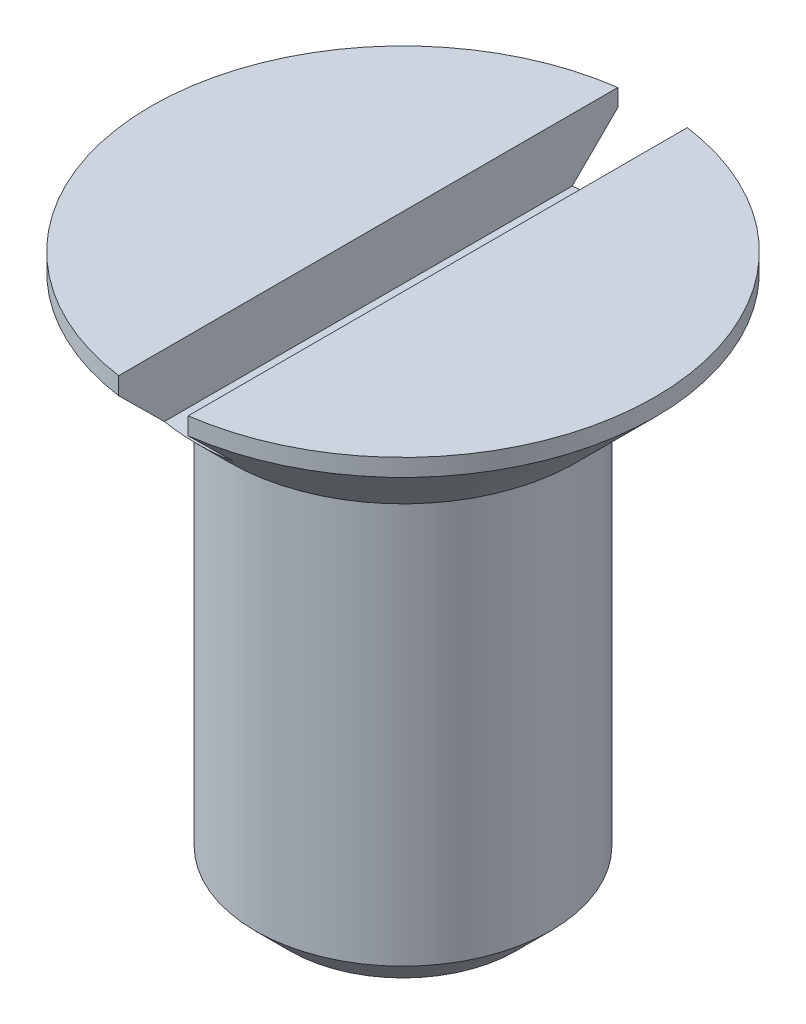
from build123d import *

# Parameters (mm, degrees)
SKETCH1_R               = 0.725
BOSS_EXTRUDE1_DEPTH     = 0.275
SKETCH2_R               = 0.425
BOSS_EXTRUDE2_DEPTH     = 1.305
CHAMFER1_SIZE           = 0.1
CHAMFER2_SIZE           = 0.225
SKETCH3_W               = 0.2
SKETCH3_H               = 0.546644051
CUT_EXTRUDE1_DEPTH      = 1.725
CUT_EXTRUDE1_DEPTH_BACK = 1.725


with BuildPart() as part:
    # Sketch1 → Boss-Extrude1 (new body)
    with BuildSketch(Plane(origin=(0, 0, 0), x_dir=(1, 0, 0), z_dir=(0, 1, 0))):
        Circle(SKETCH1_R)
    extrude(amount=BOSS_EXTRUDE1_DEPTH)

    # Sketch2 → Boss-Extrude2 (add)
    with BuildSketch(Plane(origin=(0, 0, 0), x_dir=(1, 0, 0), z_dir=(0, 1, 0))):
        Circle(SKETCH2_R)
    extrude(amount=-BOSS_EXTRUDE2_DEPTH)

    # Chamfer1
    chamfer1_edges = [part.edges().sort_by_distance(p)[0] for p in [
        (-0.425, -1.305, 0),
    ]]
    chamfer(chamfer1_edges, length=CHAMFER1_SIZE)

    # Chamfer2
    chamfer2_edges = [part.edges().sort_by_distance(p)[0] for p in [
        (-0.725, 0, 0),
    ]]
    chamfer(chamfer2_edges, length=CHAMFER2_SIZE)

    # Sketch3 → Cut-Extrude1 (cut, two sides)
    with BuildSketch(Plane.XY) as cut_extrude1_sk:
        with Locations((0, 0.368322025)):
            Rectangle(SKETCH3_W, SKETCH3_H)
    extrude(amount=CUT_EXTRUDE1_DEPTH, mode=Mode.SUBTRACT)
    extrude(cut_extrude1_sk.sketch, amount=-CUT_EXTRUDE1_DEPTH_BACK, mode=Mode.SUBTRACT)


solid = part.part
